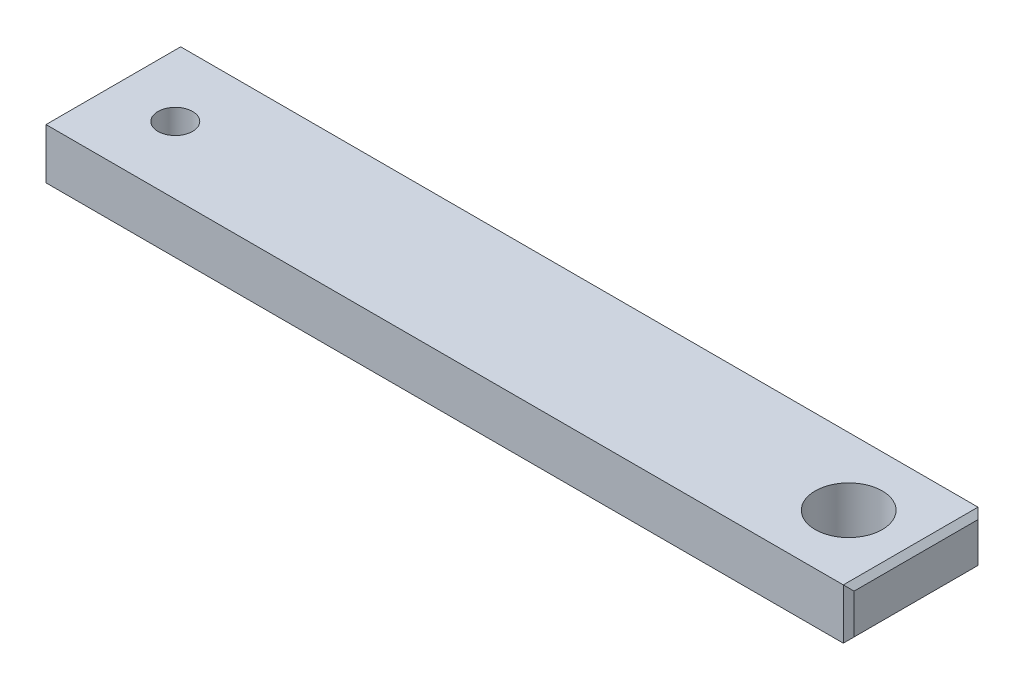
from build123d import *

# Parameters (mm, degrees)
SKETCH1_W             = 76.2
SKETCH1_H             = 12.7
BOSS_EXTRUDE2_DEPTH   = 4.7625
F_4_CLEARANCE_HOLE1_D = 3.2639
CUT_EXTRUDE1_DEPTH    = 5.7625
CHAMFER1_SIZE         = 0.508


with BuildPart() as part:
    # Sketch1 → Boss-Extrude2 (new body)
    with BuildSketch(Plane(origin=(0, 0, 0), x_dir=(1, 0, 0), z_dir=(0, 1, 0))):
        with Locations((-31.75, 0)):
            Rectangle(SKETCH1_W, SKETCH1_H)
    extrude(amount=BOSS_EXTRUDE2_DEPTH)

    # #4 Clearance Hole1 (through all)
    with Locations(Plane(origin=(0, 4.7625, 0), x_dir=(1, 0, 0), z_dir=(0, 1, 0))):
        with Locations((-63.5, 0)):
            Hole(F_4_CLEARANCE_HOLE1_D / 2)

    # Sketch2 → Cut-Extrude1 (cut, through all)
    with BuildSketch(Plane(origin=(0, 4.7625, 0), x_dir=(1, 0, 0), z_dir=(0, 1, 0))):
        with BuildLine():
            ThreePointArc((3.1623, 0), (2.236083774, 2.236083774), (0, 3.1623))
            Line((0, 3.1623), (0, -3.1623))
            ThreePointArc((0, -3.1623), (2.236083774, -2.236083774), (3.1623, 0))
        make_face()
        with BuildLine():
            Line((0, -3.1623), (0, 3.1623))
            ThreePointArc((0, 3.1623), (-3.1623, 0), (0, -3.1623))
        make_face()
    extrude(amount=-CUT_EXTRUDE1_DEPTH, mode=Mode.SUBTRACT)

    # Chamfer1
    chamfer1_edges = [part.edges().sort_by_distance(p)[0] for p in [
        (-69.85, 2.38125, 6.35),
        (-69.85, 2.38125, -6.35),
        (6.35, 2.38125, -6.35),
        (6.35, 2.38125, 6.35),
        (6.35, 4.7625, 0),
        (-69.85, 4.7625, 0),
        (-69.85, 0, 0),
        (6.35, 0, 0),
    ]]
    chamfer(chamfer1_edges, length=CHAMFER1_SIZE)


solid = part.part
